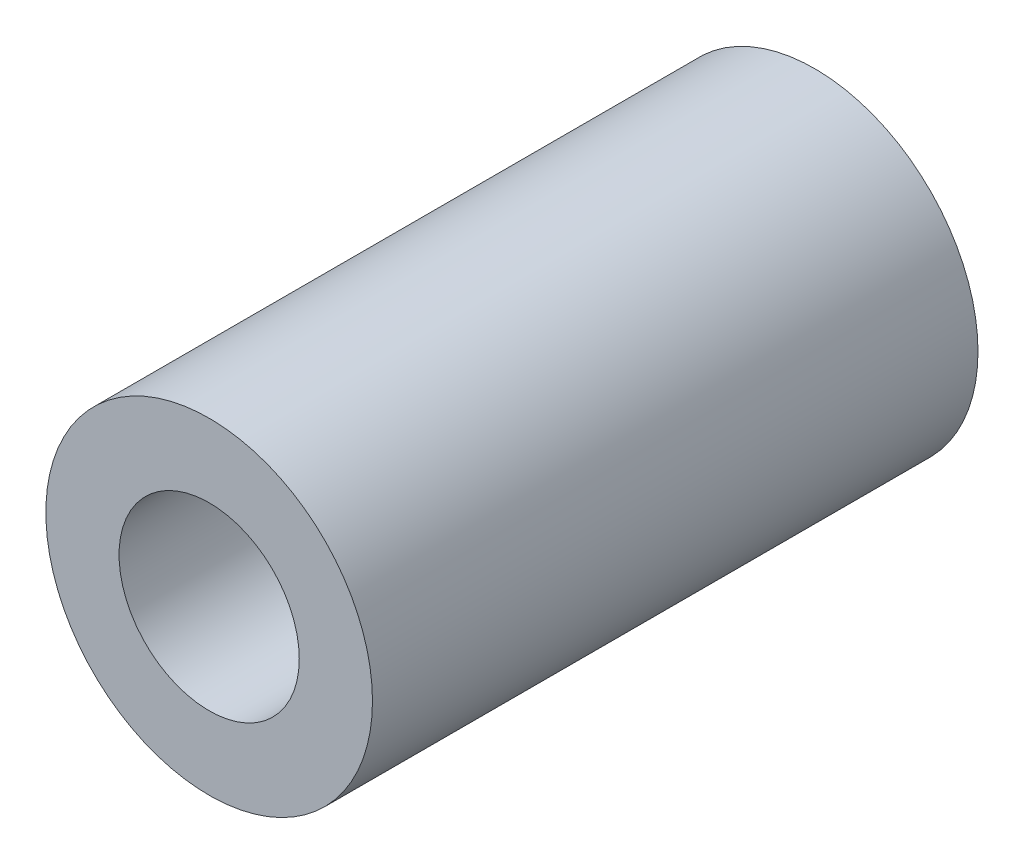
from build123d import *

# Parameters (mm, degrees)
SKETCH1_R               = 11.509375
BOSS_EXTRUDE1_DEPTH     = 42.672
SKETCH2_R               = 6.35
CUT_EXTRUDE1_DEPTH      = 1
CUT_EXTRUDE1_DEPTH_BACK = 43.672


with BuildPart() as part:
    # Sketch1 → Boss-Extrude1 (new body)
    with BuildSketch(Plane.XY):
        Circle(SKETCH1_R)
    extrude(amount=BOSS_EXTRUDE1_DEPTH)

    # Sketch2 → Cut-Extrude1 (cut, two sides)
    with BuildSketch(Plane.XY.offset(42.672)) as cut_extrude1_sk:
        Circle(SKETCH2_R)
    extrude(amount=CUT_EXTRUDE1_DEPTH, mode=Mode.SUBTRACT)
    extrude(cut_extrude1_sk.sketch, amount=-CUT_EXTRUDE1_DEPTH_BACK, mode=Mode.SUBTRACT)


solid = part.part
